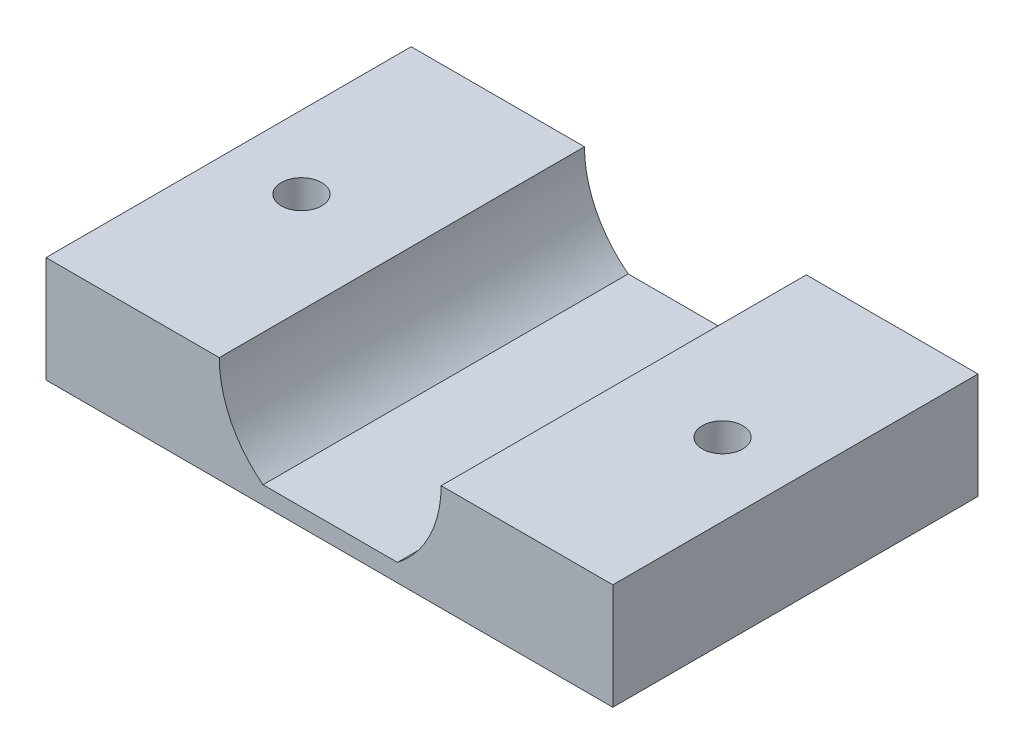
from build123d import *

# Parameters (mm, degrees)
SKETCH1_W          = 98.9
SKETCH1_H          = 124.45
BODY_DEPTH         = 22.55
SKETCH4_W          = 7
SKETCH4_H          = 3
SKETCH4_W_2        = 3
SKETCH4_H_2        = 7
CUT_EXTRUDE1_DEPTH = 63
SKETCH5_W          = 8.299397568
SKETCH5_H          = 10.9
CUT_EXTRUDE2_DEPTH = 63
SKETCH6_W          = 98.9
SKETCH6_H          = 68.5
CUT_EXTRUDE3_DEPTH = 63
SKETCH7_W          = 22.55
SKETCH7_H          = 1.441759006
CUT_EXTRUDE4_DEPTH = 63
CUT_EXTRUDE5_DEPTH = 23.55
SKETCH9_R          = 1.25
CUT_EXTRUDE6_DEPTH = 10


with BuildPart() as part:
    # Sketch1 → body (new body)
    with BuildSketch(Plane.XY):
        Rectangle(SKETCH1_W, SKETCH1_H)
    extrude(amount=BODY_DEPTH)

    # Sketch4 → Cut-Extrude1 (cut)
    with BuildSketch(Plane(origin=(0, 0, 0), x_dir=(-1, 0, 0), z_dir=(0, 0, -1))):
        with Locations((0, 62.225)):
            Rectangle(SKETCH4_W, SKETCH4_H)
        with Locations((49.35, 12.775)):
            Rectangle(SKETCH4_W_2, SKETCH4_H_2)
        with Locations((-49.45, 12.875)):
            Rectangle(SKETCH4_W_2, SKETCH4_H_2)
    extrude(amount=-CUT_EXTRUDE1_DEPTH, mode=Mode.SUBTRACT)

    # Sketch5 → Cut-Extrude2 (cut)
    with BuildSketch(Plane(origin=(0, 0, 0), x_dir=(-1, 0, 0), z_dir=(0, 0, -1))):
        with Locations((-0.05, 12.825)):
            Rectangle(SKETCH5_W, SKETCH5_H)
        with BuildLine():
            Line((4.099698784, 18.275), (4.099698784, 7.375))
            ThreePointArc((4.099698784, 7.375), (6.087912376, 9.783860137), (6.8, 12.825))
            ThreePointArc((6.8, 12.825), (6.087912376, 15.866139863), (4.099698784, 18.275))
        make_face()
        with BuildLine():
            ThreePointArc((-4.199698784, 18.275), (-6.9, 12.825), (-4.199698784, 7.375))
            Line((-4.199698784, 7.375), (-4.199698784, 18.275))
        make_face()
    extrude(amount=-CUT_EXTRUDE2_DEPTH, mode=Mode.SUBTRACT)

    # Sketch6 → Cut-Extrude3 (cut)
    with BuildSketch(Plane(origin=(0, 0, 0), x_dir=(-1, 0, 0), z_dir=(0, 0, -1))):
        with BuildLine():
            Line((49.45, 19.275), (49.45, 62.225))
            Line((49.45, 62.225), (6.5, 62.225))
            Line((6.5, 62.225), (6.5, 22.275))
            ThreePointArc((6.5, 22.275), (8.621320344, 21.396320344), (9.5, 19.275))
            Line((9.5, 19.275), (49.45, 19.275))
        make_face()
        with BuildLine():
            Line((-49.45, 60.783244994), (-49.45, 19.391375139))
            Line((-49.45, 19.391375139), (-9.597617792, 19.297494249))
            ThreePointArc((-9.597617792, 19.297494249), (-8.71394336, 21.416738793), (-6.590558988, 22.290418797))
            Line((-6.590558988, 22.290418797), (-6.496484462, 62.225))
            Line((-6.496484462, 62.225), (-49.446603635, 62.225))
            Line((-49.446603635, 62.225), (-49.45, 60.783244994))
        make_face()
        with Locations((0, -27.975)):
            Rectangle(SKETCH6_W, SKETCH6_H)
    extrude(amount=-CUT_EXTRUDE3_DEPTH, mode=Mode.SUBTRACT)

    # Sketch7 → Cut-Extrude4 (cut)
    with BuildSketch(Plane(origin=(49.592912844, 0.116826812, 0), x_dir=(0, 0, 1), z_dir=(-0.999997225, -0.002355709, 0))):
        with Locations((11.275, 61.387466016)):
            Rectangle(SKETCH7_W, SKETCH7_H)
    extrude(amount=-CUT_EXTRUDE4_DEPTH, mode=Mode.SUBTRACT)

    # Sketch8 → Cut-Extrude5 (cut, through all)
    with BuildSketch(Plane.XY.offset(22.55)):
        with BuildLine():
            Line((-49.45, 6.275), (-17.5, 6.275))
            Line((-17.5, 6.275), (-17.5, 12.825))
            Line((-17.5, 12.825), (-6.8, 12.825))
            ThreePointArc((-6.8, 12.825), (-6.087912376, 15.866139863), (-4.099698784, 18.275))
            Line((-4.099698784, 18.275), (4.199698784, 18.275))
            ThreePointArc((4.199698784, 18.275), (6.187912376, 15.866139863), (6.9, 12.825))
            Line((6.9, 12.825), (17.5, 12.825))
            Line((17.5, 12.825), (17.5, 6.275))
            Line((17.5, 6.275), (49.45, 6.275))
            Line((49.45, 6.275), (49.45, 9.375))
            Line((49.45, 9.375), (47.95, 9.375))
            Line((47.95, 9.375), (47.95, 16.375))
            Line((47.95, 16.375), (49.45, 16.375))
            Line((49.45, 16.375), (49.45, 19.391375139))
            Line((49.45, 19.391375139), (9.597617792, 19.297494249))
            ThreePointArc((9.597617792, 19.297494249), (8.71394336, 21.416738793), (6.590558988, 22.290418797))
            Line((6.590558988, 22.290418797), (6.496484462, 62.225))
            Line((6.496484462, 62.225), (3.5, 62.225))
            Line((3.5, 62.225), (3.5, 60.725))
            Line((3.5, 60.725), (-3.5, 60.725))
            Line((-3.5, 60.725), (-3.5, 62.225))
            Line((-3.5, 62.225), (-6.5, 62.225))
            Line((-6.5, 62.225), (-6.5, 22.275))
            ThreePointArc((-6.5, 22.275), (-8.621320344, 21.396320344), (-9.5, 19.275))
            Line((-9.5, 19.275), (-49.45, 19.275))
            Line((-49.45, 19.275), (-49.45, 16.275))
            Line((-49.45, 16.275), (-47.85, 16.275))
            Line((-47.85, 16.275), (-47.85, 9.275))
            Line((-47.85, 9.275), (-49.45, 9.275))
            Line((-49.45, 9.275), (-49.45, 6.275))
        make_face()
    extrude(amount=-CUT_EXTRUDE5_DEPTH, mode=Mode.SUBTRACT)

    # Sketch9 → Cut-Extrude6 (cut)
    with BuildSketch(Plane.XZ.offset(-6.275)):
        with Locations((13, 11.275)):
            Circle(SKETCH9_R)
        with Locations((-13, 11.275)):
            Circle(SKETCH9_R)
    extrude(amount=-CUT_EXTRUDE6_DEPTH, mode=Mode.SUBTRACT)


solid = part.part
